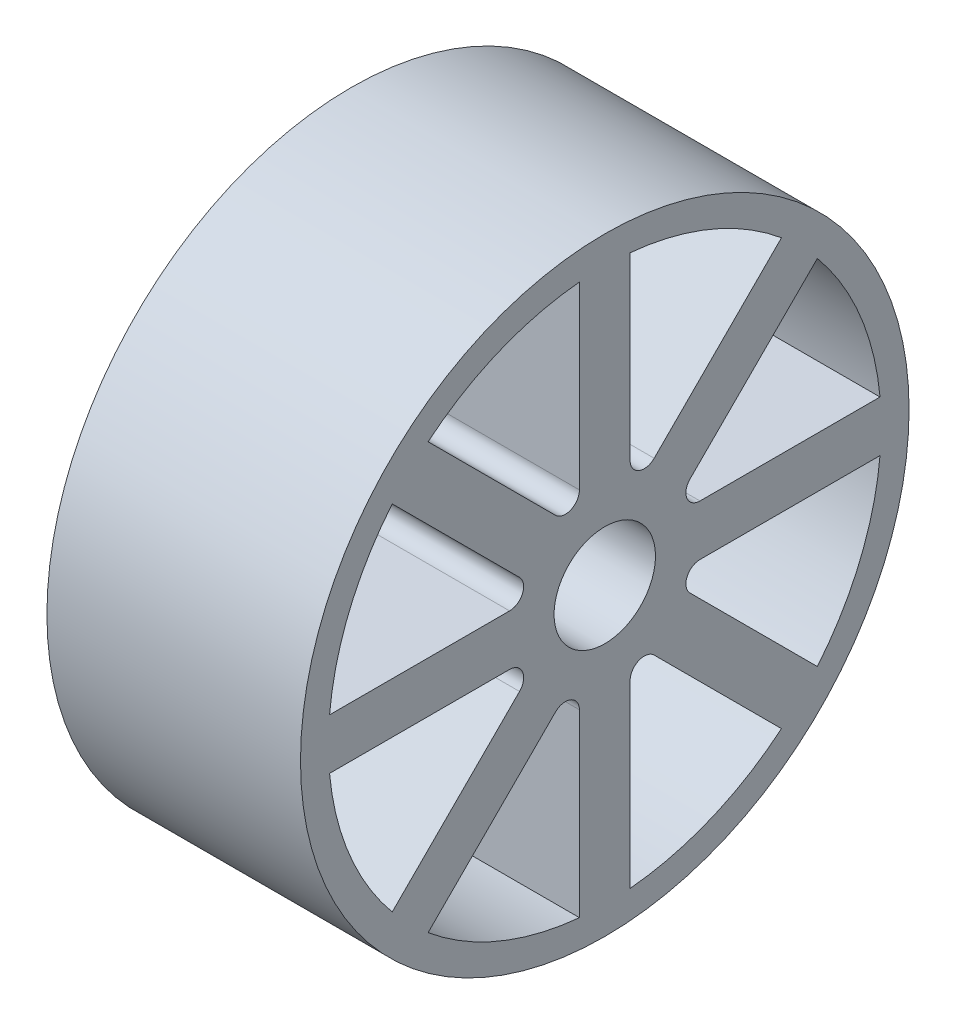
from build123d import *

# Parameters (mm, degrees)
SKETCH1_R           = 27.5
SKETCH1_R_2         = 5
BOSS_EXTRUDE1_DEPTH = 25
CUT_EXTRUDE1_DEPTH  = 25
SKETCH3_R           = 30
SKETCH3_R_2         = 27.25
BOSS_EXTRUDE2_DEPTH = 25


with BuildPart() as part:
    # Sketch1 → Boss-Extrude1 (new body)
    with BuildSketch(Plane(origin=(0, 0, 0), x_dir=(0, 0, -1), z_dir=(1, 0, 0))):
        Circle(SKETCH1_R)
        Circle(SKETCH1_R_2, mode=Mode.SUBTRACT)
    extrude(amount=BOSS_EXTRUDE1_DEPTH)

    # Sketch2 → Cut-Extrude1 (cut)
    with BuildSketch(Plane(origin=(25, 0, 0), x_dir=(0, 0, -1), z_dir=(1, 0, 0))):
        with BuildLine():
            Line((-2.5, 27.386127875), (-2.5, 9.386127875))
            ThreePointArc((-2.5, 9.386127875), (-3.356749875, 8.103911075), (-4.869227717, 8.404761623))
            Line((-4.869227717, 8.404761623), (-17.597149778, 21.132683684))
            ThreePointArc((-17.597149778, 21.132683684), (-10.670518583, 25.760910681), (-2.5, 27.386127875))
        make_face()
        with BuildLine():
            Line((17.597149778, 21.132683684), (4.869227717, 8.404761623))
            ThreePointArc((4.869227717, 8.404761623), (3.356749875, 8.103911075), (2.5, 9.386127875))
            Line((2.5, 9.386127875), (2.5, 27.386127875))
            ThreePointArc((2.5, 27.386127875), (10.670518583, 25.760910681), (17.597149778, 21.132683684))
        make_face()
        with BuildLine():
            Line((27.386127875, 2.5), (9.386127875, 2.5))
            ThreePointArc((9.386127875, 2.5), (8.103911075, 3.356749875), (8.404761623, 4.869227717))
            Line((8.404761623, 4.869227717), (21.132683684, 17.597149778))
            ThreePointArc((21.132683684, 17.597149778), (25.760910681, 10.670518583), (27.386127875, 2.5))
        make_face()
        with BuildLine():
            Line((21.132683684, -17.597149778), (8.404761623, -4.869227717))
            ThreePointArc((8.404761623, -4.869227717), (8.103911075, -3.356749875), (9.386127875, -2.5))
            Line((9.386127875, -2.5), (27.386127875, -2.5))
            ThreePointArc((27.386127875, -2.5), (25.760910681, -10.670518583), (21.132683684, -17.597149778))
        make_face()
        with BuildLine():
            Line((2.5, -27.386127875), (2.5, -9.386127875))
            ThreePointArc((2.5, -9.386127875), (3.356749875, -8.103911075), (4.869227717, -8.404761623))
            Line((4.869227717, -8.404761623), (17.597149778, -21.132683684))
            ThreePointArc((17.597149778, -21.132683684), (10.670518583, -25.760910681), (2.5, -27.386127875))
        make_face()
        with BuildLine():
            Line((-17.597149778, -21.132683684), (-4.869227717, -8.404761623))
            ThreePointArc((-4.869227717, -8.404761623), (-3.356749875, -8.103911075), (-2.5, -9.386127875))
            Line((-2.5, -9.386127875), (-2.5, -27.386127875))
            ThreePointArc((-2.5, -27.386127875), (-10.670518583, -25.760910681), (-17.597149778, -21.132683684))
        make_face()
        with BuildLine():
            Line((-27.386127875, -2.5), (-9.386127875, -2.5))
            ThreePointArc((-9.386127875, -2.5), (-8.103911075, -3.356749875), (-8.404761623, -4.869227717))
            Line((-8.404761623, -4.869227717), (-21.132683684, -17.597149778))
            ThreePointArc((-21.132683684, -17.597149778), (-25.760910681, -10.670518583), (-27.386127875, -2.5))
        make_face()
        with BuildLine():
            Line((-21.132683684, 17.597149778), (-8.404761623, 4.869227717))
            ThreePointArc((-8.404761623, 4.869227717), (-8.103911075, 3.356749875), (-9.386127875, 2.5))
            Line((-9.386127875, 2.5), (-27.386127875, 2.5))
            ThreePointArc((-27.386127875, 2.5), (-25.760910681, 10.670518583), (-21.132683684, 17.597149778))
        make_face()
    extrude(amount=-CUT_EXTRUDE1_DEPTH, mode=Mode.SUBTRACT)

    # Sketch3 → Boss-Extrude2 (add)
    with BuildSketch(Plane(origin=(25, 0, 0), x_dir=(0, 0, -1), z_dir=(1, 0, 0))):
        Circle(SKETCH3_R)
        Circle(SKETCH3_R_2, mode=Mode.SUBTRACT)
    extrude(amount=-BOSS_EXTRUDE2_DEPTH)


solid = part.part
